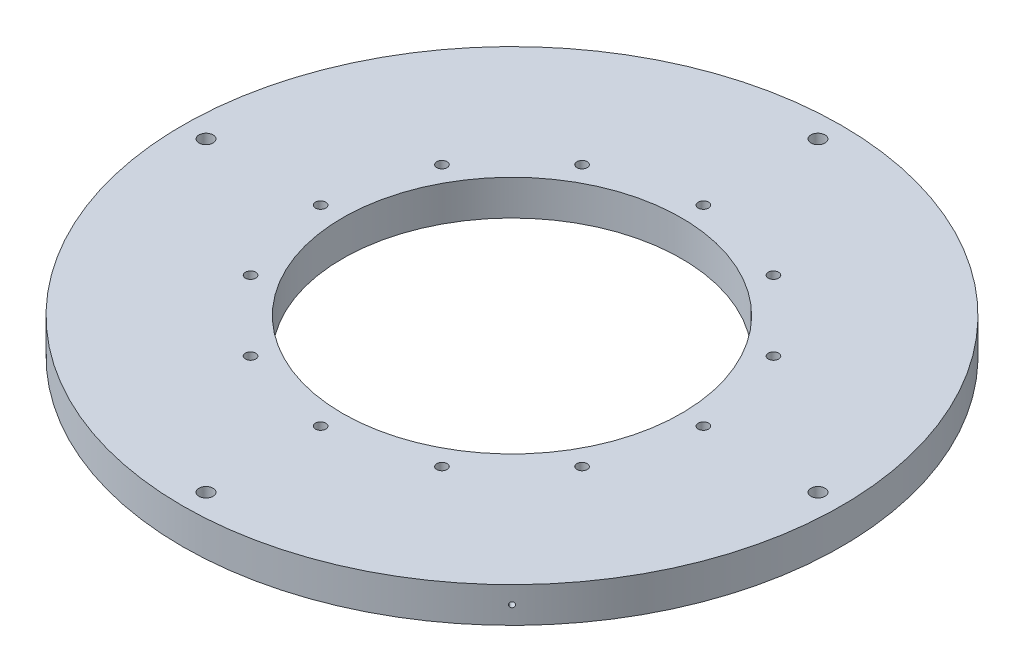
from build123d import *

# Parameters (mm, degrees)
SKETCH1_R           = 88.9
BOSS_EXTRUDE1_DEPTH = 9.525
SKETCH2_R           = 45.72
CUT_EXTRUDE1_DEPTH  = 12.7
SKETCH3_R           = 1.397
CUT_EXTRUDE2_DEPTH  = 12.7
CIRPATTERN1_COUNT   = 12
SKETCH4_R           = 1.905
CUT_EXTRUDE3_DEPTH  = 12.7
CIRPATTERN2_COUNT   = 4
SKETCH10_R          = 0.6985
CUT_EXTRUDE5_DEPTH  = 3.175
CIRPATTERN5_COUNT   = 4


with BuildPart() as part:
    # Sketch1 → Boss-Extrude1 (new body)
    with BuildSketch(Plane(origin=(0, 0, 0), x_dir=(1, 0, 0), z_dir=(0, 1, 0))):
        Circle(SKETCH1_R)
    extrude(amount=BOSS_EXTRUDE1_DEPTH)

    # Sketch2 → Cut-Extrude1 (cut)
    with BuildSketch(Plane(origin=(0, 9.525, 0), x_dir=(1, 0, 0), z_dir=(0, 1, 0))):
        Circle(SKETCH2_R)
    extrude(amount=-CUT_EXTRUDE1_DEPTH, mode=Mode.SUBTRACT)

    # Sketch3 → Cut-Extrude2 (cut)
    with BuildSketch(Plane(origin=(0, 9.525, 0), x_dir=(1, 0, 0), z_dir=(0, 1, 0))):
        with Locations((0, 51.6382)):
            Circle(SKETCH3_R)
    cut_extrude2 = extrude(amount=-CUT_EXTRUDE2_DEPTH, mode=Mode.SUBTRACT)

    # CirPattern1: Cut-Extrude2 ×12 about axis
    cirpattern1_axis = Axis((0, 0, 0), (0, 1, 0))
    for i in range(1, CIRPATTERN1_COUNT):
        add(cut_extrude2.rotate(cirpattern1_axis, i * 360 / CIRPATTERN1_COUNT), mode=Mode.SUBTRACT)

    # Sketch4 → Cut-Extrude3 (cut)
    with BuildSketch(Plane(origin=(0, 9.525, 0), x_dir=(1, 0, 0), z_dir=(0, 1, 0))):
        with Locations((0, 82.55)):
            Circle(SKETCH4_R)
    cut_extrude3 = extrude(amount=-CUT_EXTRUDE3_DEPTH, mode=Mode.SUBTRACT)

    # CirPattern2: Cut-Extrude3 ×4 about axis
    cirpattern2_axis = Axis((0, 0, 0), (0, 1, 0))
    for i in range(1, CIRPATTERN2_COUNT):
        add(cut_extrude3.rotate(cirpattern2_axis, i * 360 / CIRPATTERN2_COUNT), mode=Mode.SUBTRACT)

    # Sketch10 → Cut-Extrude5 (cut)
    with BuildSketch(Plane(origin=(-62.861792847, 0, -62.861792847), x_dir=(0, -1, 0), z_dir=(-0.707106781, 0, -0.707106781))):
        with Locations((-4.826, 0)):
            Circle(SKETCH10_R)
    cut_extrude5 = extrude(amount=-CUT_EXTRUDE5_DEPTH, mode=Mode.SUBTRACT)

    # CirPattern5: Cut-Extrude5 ×4 about axis
    cirpattern5_axis = Axis((0, 0, 0), (0, 1, 0))
    for i in range(1, CIRPATTERN5_COUNT):
        add(cut_extrude5.rotate(cirpattern5_axis, i * 360 / CIRPATTERN5_COUNT), mode=Mode.SUBTRACT)


solid = part.part
